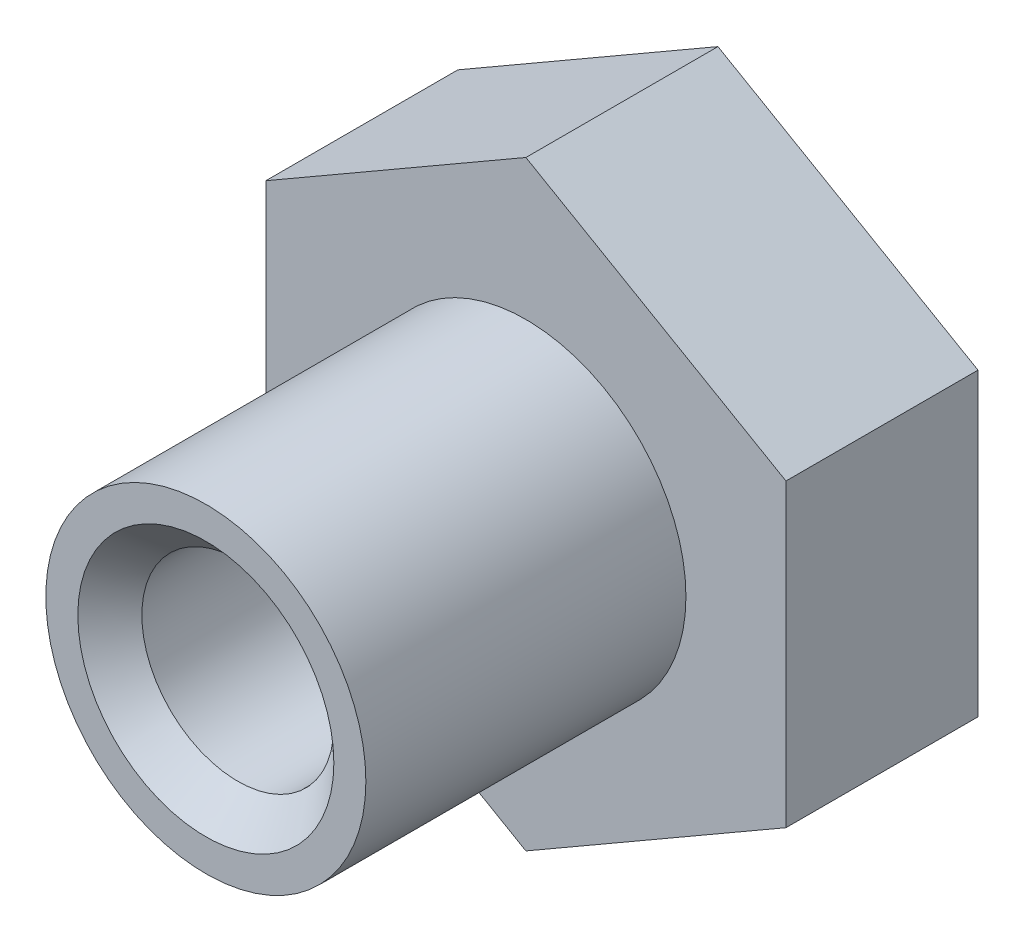
from build123d import *

# Parameters (mm, degrees)
BOSS_EXTRUDE1_DEPTH = 7.62
SKETCH2_R           = 6.35
BOSS_EXTRUDE2_DEPTH = 12.7
SKETCH3_R           = 3.81
CUT_EXTRUDE1_DEPTH  = 26.716683372
CHAMFER1_SIZE       = 1.27


with BuildPart() as part:
    # Sketch1 → Boss-Extrude1 (new body)
    with BuildSketch(Plane.XY):
        Polygon((10.31875, 5.95753309), (0, 11.91506618), (-10.31875, 5.95753309), (-10.31875, -5.95753309), (0, -11.91506618), (10.31875, -5.95753309), align=None)
    extrude(amount=BOSS_EXTRUDE1_DEPTH)

    # Sketch2 → Boss-Extrude2 (add)
    with BuildSketch(Plane.XY.offset(7.62)):
        Circle(SKETCH2_R)
    extrude(amount=BOSS_EXTRUDE2_DEPTH)

    # Sketch3 → Cut-Extrude1 (cut, through all)
    with BuildSketch(Plane.XY.offset(20.32)):
        Circle(SKETCH3_R)
    extrude(amount=-CUT_EXTRUDE1_DEPTH, mode=Mode.SUBTRACT)

    # Chamfer1
    chamfer1_edges = [part.edges().sort_by_distance(p)[0] for p in [
        (-3.81, 0, 0),
        (-3.81, 0, 20.32),
    ]]
    chamfer(chamfer1_edges, length=CHAMFER1_SIZE)


solid = part.part
